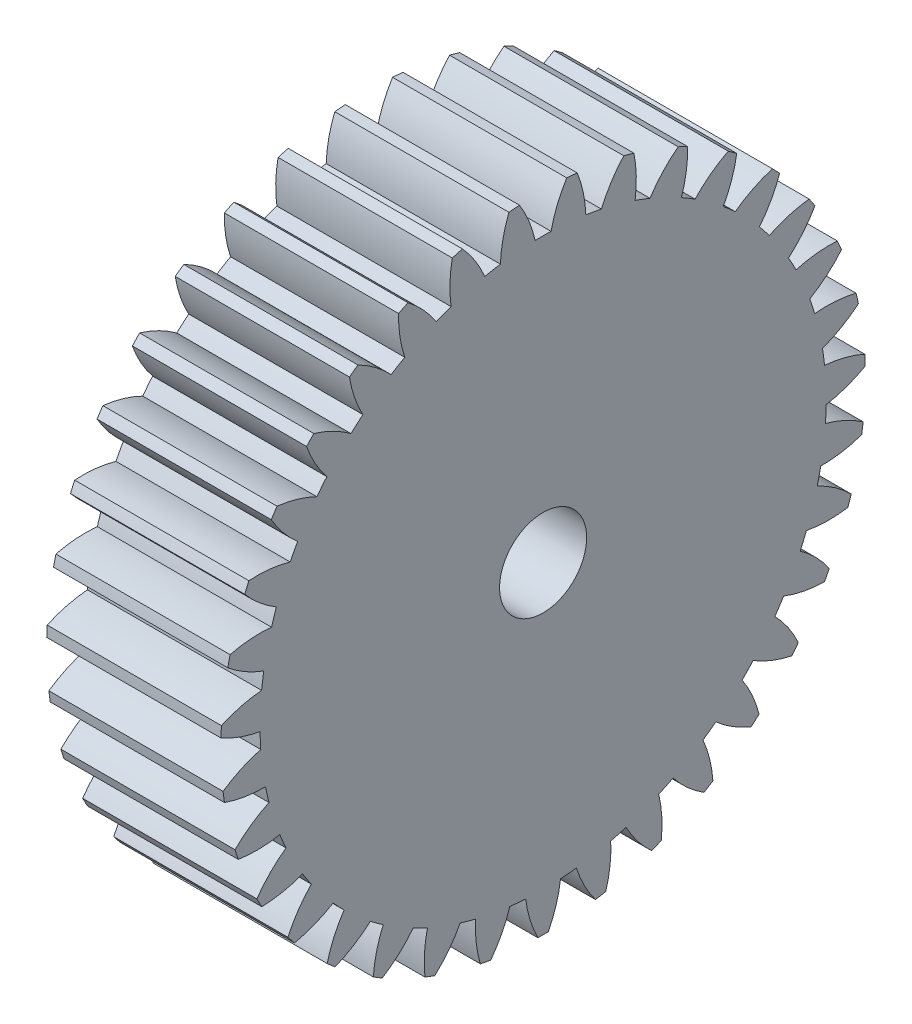
from build123d import *

# Parameters (mm, degrees)
BASPROSKE_W     = 10
BASPROSKE_H     = 18.5
TOOTHCUT_DEPTH  = 29.008927148
TEETHCUTS_COUNT = 35
TEETHCUTS_ANGLE = 349.714285714
BORSKE_R        = 2.5
BORE_DEPTH      = 50.0000508


with BuildPart() as part:
    # BasProSke → Base-Revolve (revolve)
    with BuildSketch(Plane(origin=(0, 0, 0), x_dir=(1, 0, 0), z_dir=(0, 1, 0)), mode=Mode.PRIVATE) as base_revolve_sk:
        with Locations((5, 9.25)):
            Rectangle(BASPROSKE_W, BASPROSKE_H)
    revolve(base_revolve_sk.sketch.rotate(Axis((-10, 0, 0), (1, 0, 0)), 180), axis=Axis((-10, 0, 0), (1, 0, 0)))

    # TooCutSke → ToothCut (cut, through all)
    with BuildSketch(Plane(origin=(0, 0, 0), x_dir=(0, 0, -1), z_dir=(1, 0, 0))):
        with BuildLine():
            ThreePointArc((0.456361119, 16.242590173), (0, 16.249), (-0.456361119, 16.242590173))
            ThreePointArc((-0.456361119, 16.242590173), (-0.817781123, 17.39831105), (-1.372969849, 18.474452602))
            ThreePointArc((-1.372969849, 18.474452602), (0, 18.5254), (1.372969849, 18.474452602))
            ThreePointArc((1.372969849, 18.474452602), (0.817781123, 17.39831105), (0.456361119, 16.242590173))
        make_face()
    toothcut = extrude(amount=TOOTHCUT_DEPTH, mode=Mode.SUBTRACT)

    # TeethCuts: ToothCut ×35 about axis
    teethcuts_axis = Axis((-10, 0, 0), (1, 0, 0))
    for i in range(1, TEETHCUTS_COUNT):
        add(toothcut.rotate(teethcuts_axis, i * TEETHCUTS_ANGLE / (TEETHCUTS_COUNT - 1)), mode=Mode.SUBTRACT)

    # BorSke → Bore (cut, symmetric)
    with BuildSketch(Plane(origin=(0, 0, 0), x_dir=(0, 0, -1), z_dir=(1, 0, 0))):
        with Locations(Location((0, 0, 0), (0, 0, 180))):
            Circle(BORSKE_R)
    extrude(amount=BORE_DEPTH, both=True, mode=Mode.SUBTRACT)


solid = part.part
